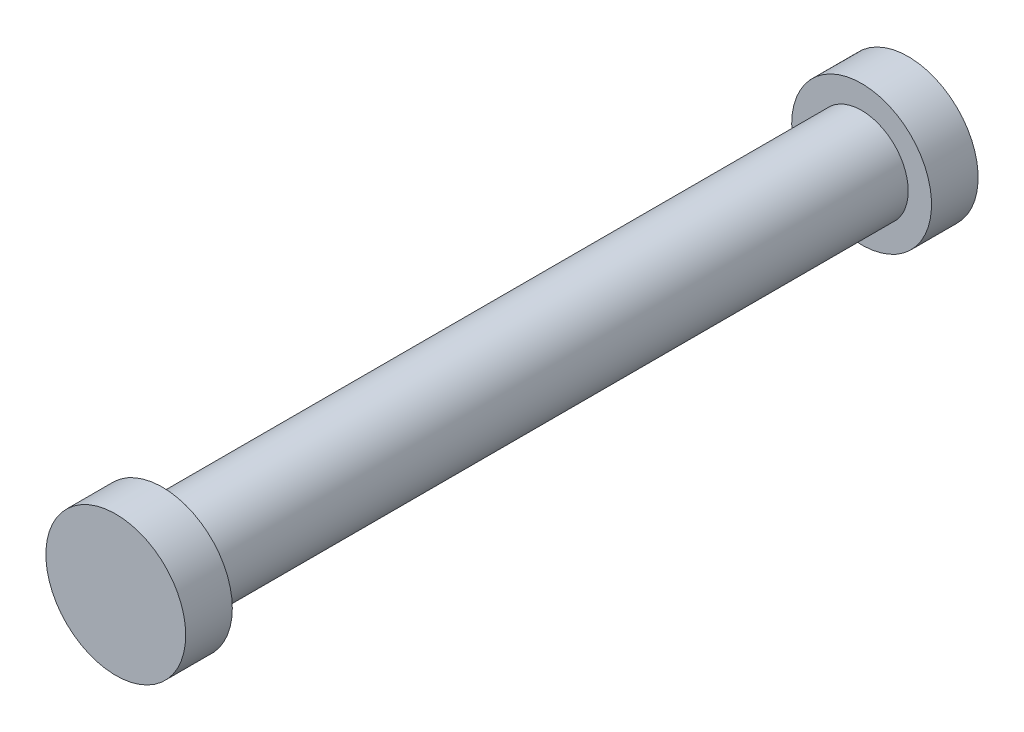
from build123d import *

# Parameters (mm, degrees)
SKETCH1_R           = 6.35
BOSS_EXTRUDE1_DEPTH = 95.25
SKETCH2_R           = 9.525
BOSS_EXTRUDE2_DEPTH = 6.35
SKETCH3_R           = 9.525
BOSS_EXTRUDE3_DEPTH = 6.35


with BuildPart() as part:
    # Sketch1 → Boss-Extrude1 (new body)
    with BuildSketch(Plane.XY):
        Circle(SKETCH1_R)
    extrude(amount=-BOSS_EXTRUDE1_DEPTH)

    # Sketch2 → Boss-Extrude2 (add)
    with BuildSketch(Plane.XY):
        Circle(SKETCH2_R)
    extrude(amount=BOSS_EXTRUDE2_DEPTH)

    # Sketch3 → Boss-Extrude3 (add)
    with BuildSketch(Plane(origin=(0, 0, -95.25), x_dir=(-1, 0, 0), z_dir=(0, 0, -1))):
        Circle(SKETCH3_R)
    extrude(amount=BOSS_EXTRUDE3_DEPTH)


solid = part.part
